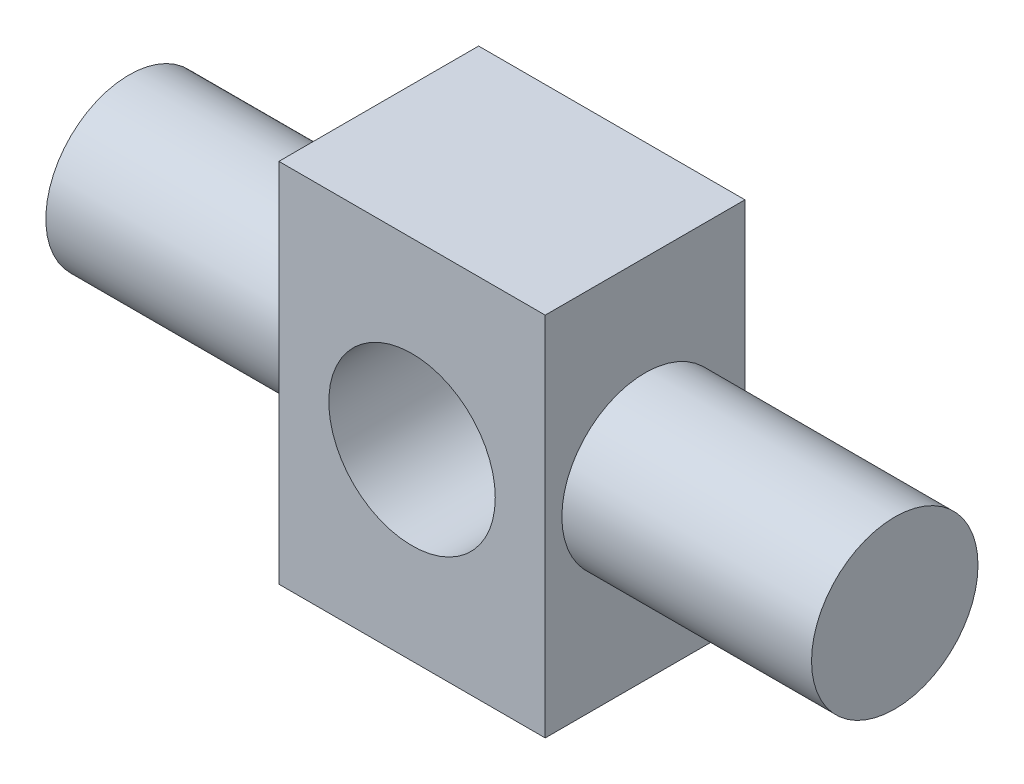
from build123d import *

# Parameters (mm, degrees)
SKETCH_1_W          = 16
SKETCH_1_H          = 22
EXTRUDE_1_DEPTH     = 6
SKETCH_2_R          = 5
EXTRUDE_2_DEPTH     = 15
SKETCH_3_R          = 5
CUT_EXTRUDE_1_DEPTH = 13


with BuildPart() as part:
    # 草图1 → 凸台-拉伸1 (new body, symmetric)
    with BuildSketch(Plane.XY):
        Rectangle(SKETCH_1_W, SKETCH_1_H)
    extrude(amount=EXTRUDE_1_DEPTH, both=True)

    # 草图2 → 凸台-拉伸2 (add)
    with BuildSketch(Plane(origin=(8, 0, 0), x_dir=(0, 0, -1), z_dir=(1, 0, 0))):
        Circle(SKETCH_2_R)
    extrude_2 = extrude(amount=EXTRUDE_2_DEPTH)

    # 镜向1: 凸台-拉伸2 across plane
    add(extrude_2.mirror(Plane(origin=(0, 0, 0), x_dir=(0, 0, 1), z_dir=(1, 0, 0))))

    # 草图3 → 切除-拉伸1 (cut, through all)
    with BuildSketch(Plane.XY.offset(6)):
        Circle(SKETCH_3_R)
    extrude(amount=-CUT_EXTRUDE_1_DEPTH, mode=Mode.SUBTRACT)


solid = part.part
